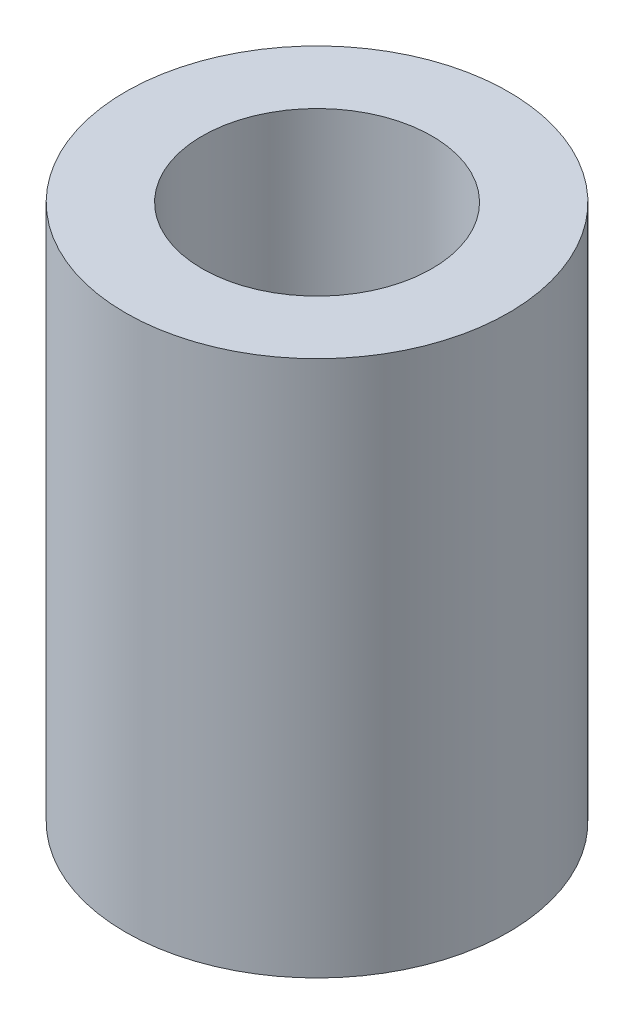
from build123d import *

# Parameters (mm, degrees)
SKETCH2_R           = 2.5
SKETCH2_R_2         = 1.5
BOSS_EXTRUDE1_DEPTH = 7


with BuildPart() as part:
    # Sketch2 → Boss-Extrude1 (new body)
    with BuildSketch(Plane(origin=(0, 0, 0), x_dir=(1, 0, 0), z_dir=(0, 1, 0))):
        Circle(SKETCH2_R)
        Circle(SKETCH2_R_2, mode=Mode.SUBTRACT)
    extrude(amount=BOSS_EXTRUDE1_DEPTH)


solid = part.part
